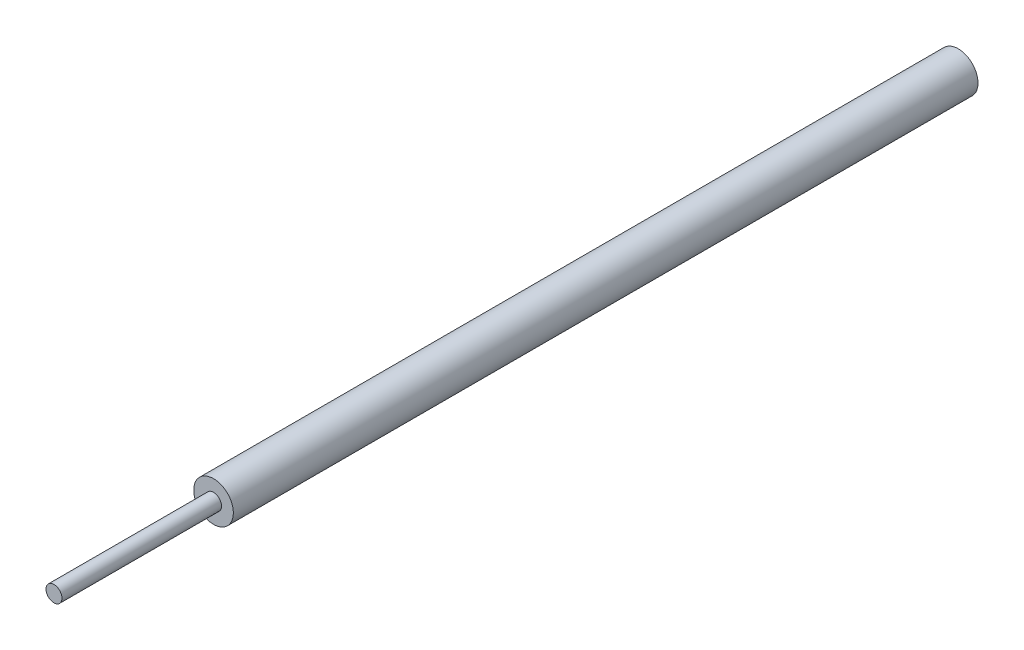
from build123d import *

# Parameters (mm, degrees)
SKETCH1_R           = 3.725
BOSS_EXTRUDE1_DEPTH = 140
SKETCH2_R           = 1.5
BOSS_EXTRUDE2_DEPTH = 30


with BuildPart() as part:
    # Sketch1 → Boss-Extrude1 (new body)
    with BuildSketch(Plane.XY):
        Circle(SKETCH1_R)
    extrude(amount=BOSS_EXTRUDE1_DEPTH)

    # Sketch2 → Boss-Extrude2 (add)
    with BuildSketch(Plane.XY.offset(140)):
        Circle(SKETCH2_R)
    extrude(amount=BOSS_EXTRUDE2_DEPTH)


solid = part.part
